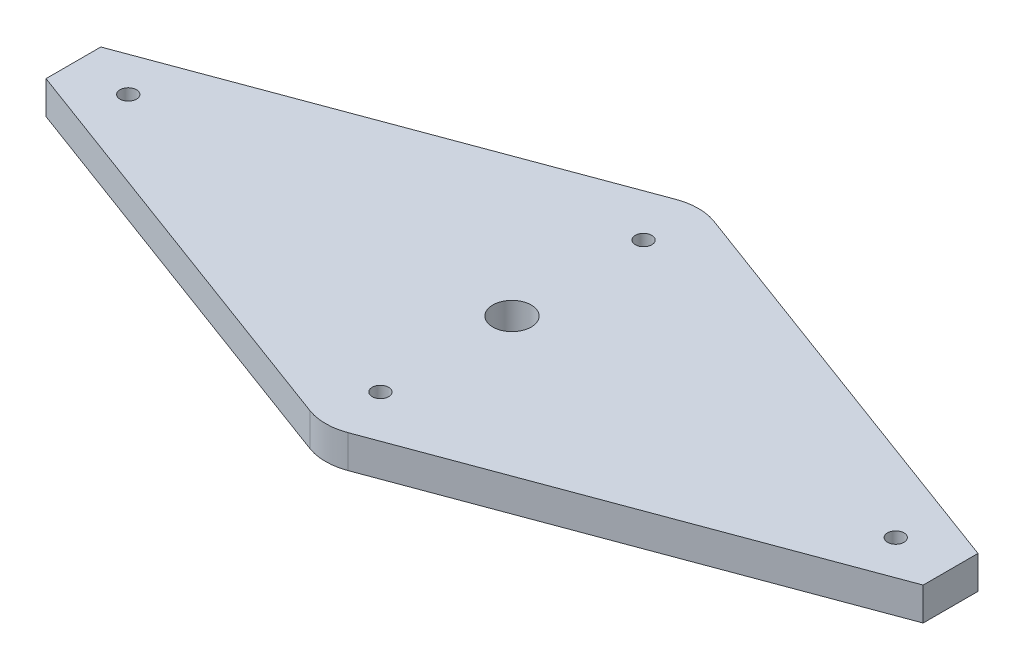
from build123d import *

# Parameters (mm, degrees)
SKETCH1_R      = 0.75
SKETCH1_R_2    = 1.75
EXTRUDE1_DEPTH = 1.5


with BuildPart() as part:
    # Sketch1 → Extrude1 (new body, symmetric)
    with BuildSketch(Plane(origin=(0, 0, 0), x_dir=(1, 0, 0), z_dir=(0, 1, 0))):
        with BuildLine():
            Line((-1.738414467, 16.688060915), (-40, 2.5))
            Line((-40, 2.5), (-40, -2.5))
            Line((-40, -2.5), (-1.738414467, -16.688060915))
            ThreePointArc((-1.738414467, -16.688060915), (0, -17), (1.738414467, -16.688060915))
            Line((1.738414467, -16.688060915), (40, -2.5))
            Line((40, -2.5), (40, 2.5))
            Line((40, 2.5), (1.738414467, 16.688060915))
            ThreePointArc((1.738414467, 16.688060915), (0, 17), (-1.738414467, 16.688060915))
        make_face()
        with Locations(Location((0, 12, 0), (0, 0, 270))):  # turned: the seam where the file's is
            Circle(SKETCH1_R, mode=Mode.SUBTRACT)
        with Locations(Location((0, -12, 0), (0, 0, 270))):  # turned: the seam where the file's is
            Circle(SKETCH1_R, mode=Mode.SUBTRACT)
        with Locations(Location((35, 0, 0), (0, 0, 270))):  # turned: the seam where the file's is
            Circle(SKETCH1_R, mode=Mode.SUBTRACT)
        with Locations(Location((-35, 0, 0), (0, 0, 270))):  # turned: the seam where the file's is
            Circle(SKETCH1_R, mode=Mode.SUBTRACT)
        with Locations(Location((0, 0, 0), (0, 0, 270))):  # turned: the seam where the file's is
            Circle(SKETCH1_R_2, mode=Mode.SUBTRACT)
    extrude(amount=EXTRUDE1_DEPTH, both=True)


solid = part.part
